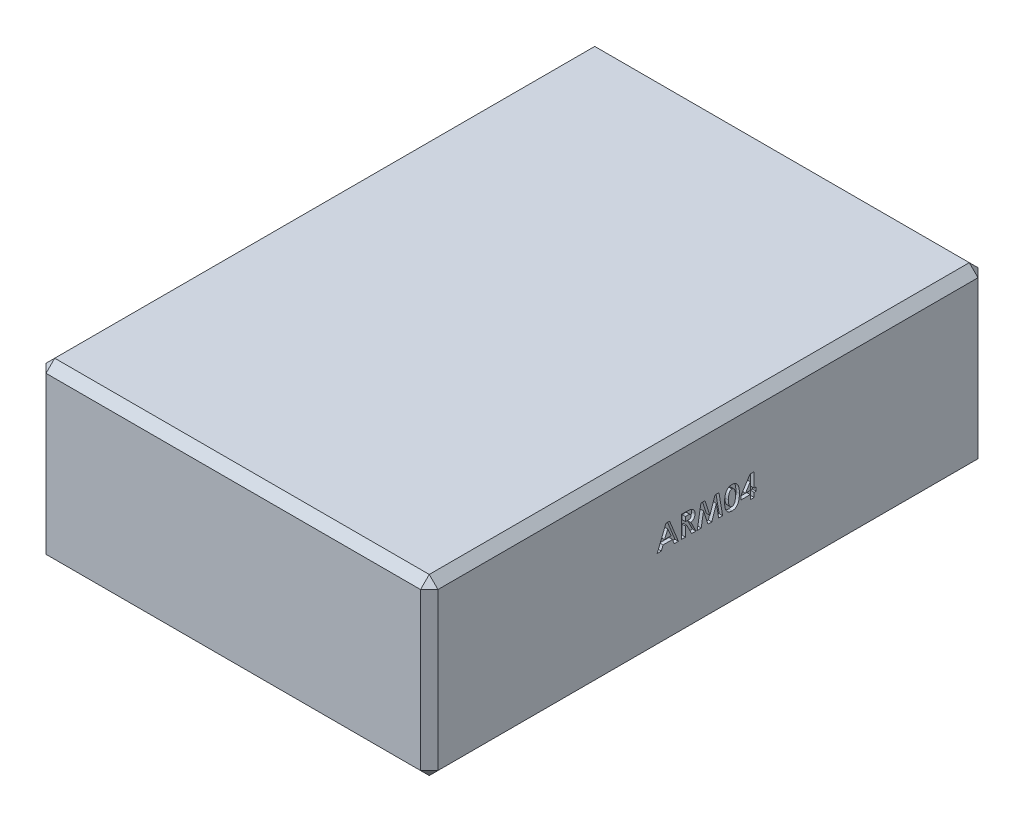
from build123d import *

# Parameters (mm, degrees)
SKETCH2_W           = 57.15
SKETCH2_H           = 25.4
BOSS_EXTRUDE1_DEPTH = 81.28
CUT_EXTRUDE1_DEPTH  = 78.74
CHAMFER1_SIZE       = 1.27
CUT_EXTRUDE2_DEPTH  = 0.508
CUT_EXTRUDE3_DEPTH  = 0.508
CHAMFER2_SIZE       = 0.508


with BuildPart() as part:
    # Sketch2 → Boss-Extrude1 (new body)
    with BuildSketch(Plane.XY):
        with Locations((0, 12.7)):
            Rectangle(SKETCH2_W, SKETCH2_H)
    extrude(amount=-BOSS_EXTRUDE1_DEPTH)

    # Sketch4 → Cut-Extrude1 (cut)
    with BuildSketch(Plane(origin=(0, 0, -81.28), x_dir=(-1, 0, 0), z_dir=(0, 0, -1))):
        with BuildLine():
            Line((-7.02184978, 0), (7.02184978, 0))
            ThreePointArc((7.02184978, 0), (6.384128426, 0.344920302), (6.323737891, 1.067423952))
            Line((6.323737891, 1.067423952), (10.301739912, 10.16))
            Line((10.301739912, 10.16), (-10.301739912, 10.16))
            Line((-10.301739912, 10.16), (-6.323737891, 1.067423952))
            ThreePointArc((-6.323737891, 1.067423952), (-6.384128426, 0.344920302), (-7.02184978, 0))
        make_face()
    extrude(amount=-CUT_EXTRUDE1_DEPTH, mode=Mode.SUBTRACT)

    # Chamfer1
    chamfer1_edges = [part.edges().sort_by_distance(p)[0] for p in [
        (28.575, 12.7, -81.28),
        (0, 25.4, -81.28),
        (-28.575, 12.7, -81.28),
        (0, 25.4, 0),
        (28.575, 12.7, 0),
        (0, 0, 0),
        (-28.575, 12.7, 0),
        (-28.575, 25.4, -40.64),
        (28.575, 25.4, -40.64),
        (28.575, 0, -40.64),
        (-28.575, 0, -40.64),
    ]]
    chamfer(chamfer1_edges, length=CHAMFER1_SIZE)

    # Sketch5 → Cut-Extrude2 (cut)
    with BuildSketch(Plane(origin=(28.575, 0, 0), x_dir=(0, 0, -1), z_dir=(1, 0, 0))):
        Polygon((34.514514223, 15.875), (35.043044872, 15.875), (36.32525641, 12.7), (35.71658754, 12.7), (35.4698127, 13.351282051), (34.086474359, 13.351282051), (33.839699519, 12.7), (33.231666667, 12.7), align=None)
        Polygon((34.778461538, 15.023372396), (34.302720353, 13.921153846), (35.254202724, 13.921153846), align=None, mode=Mode.SUBTRACT)
        with BuildLine():
            Line((36.793365385, 15.875), (37.457367788, 15.875))
            add(Edge.make_bspline(
                [(37.457367788, 15.875), (37.501258145, 15.874844214), (37.585671665, 15.874544595), (37.707391349, 15.869817392), (37.819207618, 15.863239101), (37.921286026, 15.853200455), (38.013582903, 15.839890424), (38.09619075, 15.824200099), (38.169107155, 15.80631761), (38.232947065, 15.784034619), (38.290559427, 15.758899742), (38.344262158, 15.730019307), (38.395240021, 15.697714908), (38.443152282, 15.661136528), (38.488415312, 15.620942202), (38.5311145, 15.577091473), (38.57064647, 15.529212502), (38.606766436, 15.477607826), (38.639686877, 15.42332089), (38.668781643, 15.366277157), (38.692441555, 15.306436959), (38.713347623, 15.244665114), (38.728405587, 15.180078583), (38.73887818, 15.113306125), (38.746545804, 15.044112696), (38.746986655, 14.997105753), (38.747211538, 14.973127003)],
                knots=[0, 0, 0, 0, 0.000131662, 0.000253223, 0.00036538, 0.000467651, 0.000560835, 0.000645033, 0.000719848, 0.000785822, 0.000847624, 0.000908233, 0.000968574, 0.001028488, 0.00108886, 0.00115003, 0.00121192, 0.001274915, 0.001338834, 0.001402263, 0.001466749, 0.001531714, 0.00159774, 0.001665392, 0.001734437, 0.001806332, 0.001806332, 0.001806332, 0.001806332], degree=3))
            add(Edge.make_bspline(
                [(38.747211538, 14.973127003), (38.746627373, 14.948098697), (38.74548193, 14.899022751), (38.739311954, 14.826934188), (38.728035176, 14.757964894), (38.710954855, 14.692316801), (38.691323244, 14.629172843), (38.665218237, 14.569698066), (38.635756158, 14.513027495), (38.600764906, 14.459962756), (38.562363717, 14.409325176), (38.517703942, 14.363054868), (38.469678848, 14.318664978), (38.41558877, 14.278935939), (38.357818049, 14.241181417), (38.295218842, 14.206965765), (38.228199692, 14.175428881), (38.18108191, 14.157841737), (38.156987179, 14.148848157)],
                knots=[0, 0, 0, 0, 7.5093e-05, 0.000147244, 0.000216881, 0.000284446, 0.00035062, 0.000415008, 0.000479022, 0.000542001, 0.000605481, 0.000669369, 0.000734656, 0.000801438, 0.000870416, 0.000941581, 0.001015277, 0.001092403, 0.001092403, 0.001092403, 0.001092403], degree=3))
            Line((38.156987179, 14.148848157), (38.889679487, 12.7))
            Line((38.889679487, 12.7), (38.256205929, 12.7))
            Line((38.256205929, 12.7), (37.556586538, 14.083974359))
            Line((37.556586538, 14.083974359), (37.363237179, 14.083974359))
            Line((37.363237179, 14.083974359), (37.363237179, 12.7))
            Line((37.363237179, 12.7), (36.793365385, 12.7))
            Line((36.793365385, 12.7), (36.793365385, 15.875))
        make_face()
        with BuildLine():
            Line((37.363237179, 14.653846154), (37.585207332, 14.653846154))
            add(Edge.make_bspline(
                [(37.585207332, 14.653846154), (37.612345028, 14.654151797), (37.664307885, 14.654737037), (37.739037299, 14.657451626), (37.806909428, 14.663992443), (37.868215739, 14.672256521), (37.92326472, 14.681798593), (37.971565353, 14.69547296), (38.013861877, 14.710125392), (38.049653077, 14.728334563), (38.080232255, 14.74904234), (38.106635419, 14.772566889), (38.128474621, 14.79979356), (38.146449398, 14.829982448), (38.160431821, 14.863400567), (38.170637918, 14.899681062), (38.176341617, 14.939237214), (38.176997847, 14.966536345), (38.177339744, 14.980759215)],
                knots=[0, 0, 0, 0, 8.142e-05, 0.000155902, 0.000224253, 0.000285868, 0.000341504, 0.000391652, 0.000436319, 0.000475572, 0.000511736, 0.000546861, 0.000581229, 0.000616025, 0.000651936, 0.00068959, 0.000728807, 0.000771463, 0.000771463, 0.000771463, 0.000771463], degree=3))
            add(Edge.make_bspline(
                [(38.177339744, 14.980759215), (38.176693357, 14.997585908), (38.175423651, 15.03063883), (38.162824219, 15.078223447), (38.142768645, 15.122266266), (38.115277946, 15.16256829), (38.080656985, 15.197899827), (38.040926701, 15.229044858), (37.995229618, 15.253672018), (37.952917558, 15.26991583), (37.914423473, 15.279634671), (37.879683776, 15.286877065), (37.839454998, 15.292009958), (37.793706768, 15.297454304), (37.7425557, 15.300984687), (37.68572299, 15.303561163), (37.623371862, 15.304615326), (37.579907203, 15.304952323), (37.557222556, 15.305128205)],
                knots=[0, 0, 0, 0, 5.039e-05, 9.8982e-05, 0.000146513, 0.000195026, 0.000244505, 0.000294375, 0.000345896, 0.000399642, 0.000429878, 0.000464928, 0.000506034, 0.000551477, 0.000603136, 0.000659798, 0.000722141, 0.000790198, 0.000790198, 0.000790198, 0.000790198], degree=3))
            Line((37.557222556, 15.305128205), (37.363237179, 15.305128205))
            Line((37.363237179, 15.305128205), (37.363237179, 14.653846154))
        make_face(mode=Mode.SUBTRACT)
        Polygon((39.609015425, 15.875), (40.200511819, 15.875), (40.924935897, 13.660386619), (41.654448117, 15.875), (42.240220353, 15.875), (42.777019231, 12.7), (42.200151242, 12.7), (41.861153846, 14.705363582), (41.200967548, 12.7), (40.645088141, 12.7), (39.988717949, 14.705363582), (39.650356571, 12.7), (39.072852564, 12.7), align=None)
        with BuildLine():
            add(Edge.make_bspline(
                [(44.131100761, 15.956410256), (44.158684921, 15.956000762), (44.21292275, 15.955195586), (44.292804862, 15.946474876), (44.369753423, 15.933300314), (44.444069463, 15.914926396), (44.515218049, 15.890609168), (44.583717015, 15.861501864), (44.648751025, 15.826077745), (44.71114947, 15.786064384), (44.770888315, 15.740763586), (44.826531778, 15.689118337), (44.879096027, 15.632316997), (44.92744324, 15.569500832), (44.97264408, 15.50124122), (45.014550024, 15.427527338), (45.052840274, 15.347998406), (45.08794397, 15.262510908), (45.119333806, 15.169783423), (45.145773426, 15.068752326), (45.168449824, 14.959394546), (45.187590305, 14.841437874), (45.202057414, 14.714725518), (45.211808537, 14.579341659), (45.218500219, 14.435547297), (45.219046347, 14.336905546), (45.219326923, 14.286227965)],
                knots=[0, 0, 0, 0, 8.2721e-05, 0.000162652, 0.000240761, 0.00031681, 0.000392032, 0.000466108, 0.000539812, 0.00061391, 0.000688327, 0.000764397, 0.000841366, 0.000920242, 0.001001915, 0.001086799, 0.001174413, 0.001266539, 0.001363885, 0.001467866, 0.001579631, 0.001698831, 0.001826241, 0.001962095, 0.002105975, 0.002257996, 0.002257996, 0.002257996, 0.002257996], degree=3))
            add(Edge.make_bspline(
                [(45.219326923, 14.286227965), (45.219023697, 14.23491635), (45.218434533, 14.135218804), (45.212086712, 13.990109226), (45.201155464, 13.853742398), (45.187066483, 13.72613243), (45.167768433, 13.60734671), (45.145167733, 13.497077662), (45.118310772, 13.395365257), (45.085886965, 13.302438674), (45.050995752, 13.216801041), (45.012600762, 13.137427172), (44.971371215, 13.064102077), (44.928252792, 12.99571955), (44.880881582, 12.93429547), (44.831563276, 12.8777411), (44.778150466, 12.828210667), (44.722892039, 12.783151595), (44.663763654, 12.744211514), (44.601375088, 12.710155161), (44.53461406, 12.682531414), (44.46469751, 12.658505754), (44.390433697, 12.641257923), (44.313002662, 12.627572336), (44.231530225, 12.620008841), (44.176060508, 12.619070539), (44.14763722, 12.618589744)],
                knots=[0, 0, 0, 0, 0.000153928, 0.00029908, 0.000435616, 0.00056429, 0.000684118, 0.000796506, 0.00090188, 0.000999431, 0.001091557, 0.001179171, 0.001263742, 0.00134384, 0.001421437, 0.001496228, 0.001568669, 0.00163969, 0.001709897, 0.001780758, 0.001852581, 0.001926394, 0.002002291, 0.002081026, 0.002162161, 0.002247425, 0.002247425, 0.002247425, 0.002247425], degree=3))
            add(Edge.make_bspline(
                [(44.14763722, 12.618589744), (44.119214699, 12.619079814), (44.063535398, 12.620039854), (43.981842651, 12.627516098), (43.904001271, 12.641313364), (43.829149911, 12.65863817), (43.757809527, 12.682478255), (43.689638042, 12.710928485), (43.625159637, 12.744772343), (43.564195781, 12.78380315), (43.506954621, 12.828560743), (43.452546632, 12.878566389), (43.401092165, 12.933693336), (43.353373972, 12.994559051), (43.308610566, 13.060351105), (43.267268759, 13.131820811), (43.229373397, 13.208864109), (43.193739104, 13.291588392), (43.162777415, 13.381774617), (43.135222949, 13.480228137), (43.112651055, 13.587769642), (43.094497228, 13.704364584), (43.080003223, 13.829765951), (43.069221349, 13.964034271), (43.062838268, 14.107232083), (43.062255283, 14.205659072), (43.061955128, 14.256335136)],
                knots=[0, 0, 0, 0, 8.5264e-05, 0.000167032, 0.000245767, 0.000322282, 0.000397303, 0.00047113, 0.000543675, 0.00061548, 0.000687997, 0.000761371, 0.000836975, 0.000913956, 0.000993163, 0.001075524, 0.001161424, 0.001250616, 0.001345556, 0.001447249, 0.001557148, 0.001674991, 0.001801138, 0.001935772, 0.002079018, 0.002231038, 0.002231038, 0.002231038, 0.002231038], degree=3))
            add(Edge.make_bspline(
                [(43.061955128, 14.256335136), (43.062498831, 14.326745538), (43.063547914, 14.462603314), (43.076842655, 14.6588783), (43.096355963, 14.840300526), (43.125016391, 15.006566515), (43.160454613, 15.158292069), (43.205835102, 15.294477699), (43.257497488, 15.417007839), (43.301520477, 15.489595432), (43.322722356, 15.524554287)],
                knots=[0, 0, 0, 0, 0.000211192, 0.000407498, 0.000589902, 0.000758352, 0.000913387, 0.00105679, 0.00118866, 0.001311174, 0.001311174, 0.001311174, 0.001311174], degree=3))
            add(Edge.make_bspline(
                [(43.322722356, 15.524554287), (43.34737489, 15.558897855), (43.395575452, 15.626046298), (43.479855482, 15.714199652), (43.570403401, 15.789592717), (43.669079012, 15.850519281), (43.774321719, 15.898565973), (43.887035084, 15.932500812), (44.006802876, 15.952272829), (44.089049416, 15.955010519), (44.131100761, 15.956410256)],
                knots=[0, 0, 0, 0, 0.000126695, 0.000247714, 0.000364736, 0.00047928, 0.000594555, 0.000710851, 0.000831409, 0.000957535, 0.000957535, 0.000957535, 0.000957535], degree=3))
        make_face()
        with BuildLine():
            add(Edge.make_bspline(
                [(44.145093149, 15.386538462), (44.12015684, 15.38535653), (44.071268436, 15.383039317), (44.000329033, 15.363369447), (43.933437605, 15.332988272), (43.882555083, 15.296429277), (43.844470021, 15.261383097), (43.817859715, 15.229667444), (43.792198269, 15.194275061), (43.769532787, 15.153608871), (43.748130656, 15.109130059), (43.727214323, 15.060636719), (43.710068423, 15.006937747), (43.69322303, 14.948947646), (43.678464894, 14.885063142), (43.666100811, 14.81476205), (43.65505459, 14.737587196), (43.647349719, 14.65348803), (43.640166467, 14.562552541), (43.635017172, 14.46457816), (43.632864381, 14.359591317), (43.632180074, 14.287288437), (43.631826923, 14.24997496)],
                knots=[0, 0, 0, 0, 7.4685e-05, 0.000146423, 0.000219274, 0.000294097, 0.000333247, 0.000374294, 0.000418064, 0.000464213, 0.000513709, 0.000566156, 0.000622471, 0.000682665, 0.000747308, 0.000819042, 0.000896756, 0.000981117, 0.001072336, 0.001170415, 0.001275389, 0.001387335, 0.001387335, 0.001387335, 0.001387335], degree=3))
            add(Edge.make_bspline(
                [(43.631826923, 14.24997496), (43.632408167, 14.201633547), (43.633522747, 14.108935302), (43.639360392, 13.975631999), (43.651061466, 13.85431526), (43.665615241, 13.744162875), (43.686056612, 13.645889213), (43.709575732, 13.558564514), (43.738619754, 13.483301955), (43.772185718, 13.41901307), (43.809361535, 13.36432265), (43.84971752, 13.317835547), (43.891879697, 13.277579908), (43.937164082, 13.244880749), (43.985462643, 13.219821621), (44.036372174, 13.201796899), (44.089925028, 13.190763217), (44.12659747, 13.1892332), (44.145093149, 13.188461538)],
                knots=[0, 0, 0, 0, 0.000145034, 0.000278114, 0.000400132, 0.000510587, 0.000611248, 0.00070106, 0.000781611, 0.000852734, 0.000918182, 0.000979511, 0.001037105, 0.001092704, 0.001146469, 0.001199777, 0.001254286, 0.001309751, 0.001309751, 0.001309751, 0.001309751], degree=3))
            add(Edge.make_bspline(
                [(44.145093149, 13.188461538), (44.162954115, 13.188989566), (44.197923664, 13.19002338), (44.248917099, 13.200635332), (44.297140115, 13.217888063), (44.342447111, 13.242293261), (44.385000144, 13.273328205), (44.424591241, 13.311129275), (44.460921814, 13.35607326), (44.48208817, 13.389428344), (44.492994792, 13.406615585)],
                knots=[0, 0, 0, 0, 5.352e-05, 0.000104786, 0.000155484, 0.000206702, 0.000258607, 0.000313041, 0.000370455, 0.00043149, 0.00043149, 0.00043149, 0.00043149], degree=3))
            add(Edge.make_bspline(
                [(44.492994792, 13.406615585), (44.505835501, 13.4301014), (44.532761428, 13.47934925), (44.563920158, 13.562453161), (44.590147839, 13.656180636), (44.612721621, 13.760823366), (44.628160711, 13.876794074), (44.641456837, 14.00335738), (44.647869888, 14.141150605), (44.648913006, 14.236614248), (44.649455128, 14.286227965)],
                knots=[0, 0, 0, 0, 8.0219e-05, 0.000168213, 0.000265448, 0.000372104, 0.000489035, 0.00061624, 0.000753798, 0.000902648, 0.000902648, 0.000902648, 0.000902648], degree=3))
            add(Edge.make_bspline(
                [(44.649455128, 14.286227965), (44.649245718, 14.336272352), (44.64884264, 14.432599256), (44.641447314, 14.570887857), (44.631148759, 14.697191543), (44.616084946, 14.81122833), (44.596702612, 14.913275048), (44.572813812, 15.003325026), (44.544650694, 15.081555737), (44.511252592, 15.147889172), (44.47426212, 15.204263493), (44.434995604, 15.252628288), (44.39328701, 15.293920929), (44.349206089, 15.328296808), (44.301732571, 15.354562559), (44.251773263, 15.373108351), (44.199225745, 15.384327934), (44.163380899, 15.385791673), (44.145093149, 15.386538462)],
                knots=[0, 0, 0, 0, 0.000150112, 0.000288941, 0.000415335, 0.000530201, 0.000633857, 0.000726735, 0.000809439, 0.000882824, 0.000948976, 0.001011358, 0.001069375, 0.001124712, 0.001178518, 0.001231446, 0.001284085, 0.001338916, 0.001338916, 0.001338916, 0.001338916], degree=3))
        make_face(mode=Mode.SUBTRACT)
        Polygon((46.782658253, 15.956410256), (47.376698718, 15.956410256), (47.376698718, 13.880448718), (47.661634615, 13.880448718), (47.661634615, 13.351282051), (47.376698718, 13.351282051), (47.376698718, 12.7), (46.806826923, 12.7), (46.806826923, 13.351282051), (45.463557692, 13.351282051), (45.463557692, 13.92815004), align=None)
        Polygon((46.806826923, 13.880448718), (46.806826923, 14.961042668), (46.104027444, 13.880448718), align=None, mode=Mode.SUBTRACT)
    extrude(amount=-CUT_EXTRUDE2_DEPTH, mode=Mode.SUBTRACT)

    # Sketch6 → Cut-Extrude3 (cut)
    with BuildSketch(Plane.ZY.offset(28.575)):
        Polygon((-46.765485777, 15.875), (-46.236955128, 15.875), (-44.95474359, 12.7), (-45.56341246, 12.7), (-45.8101873, 13.351282051), (-47.193525641, 13.351282051), (-47.440300481, 12.7), (-48.048333333, 12.7), align=None)
        Polygon((-46.501538462, 15.023372396), (-46.977279647, 13.921153846), (-46.025797276, 13.921153846), align=None, mode=Mode.SUBTRACT)
        with BuildLine():
            Line((-44.486634615, 15.875), (-43.822632212, 15.875))
            add(Edge.make_bspline(
                [(-43.822632212, 15.875), (-43.778741855, 15.874844214), (-43.694328335, 15.874544595), (-43.572608651, 15.869817392), (-43.460792382, 15.863239101), (-43.358713974, 15.853200455), (-43.266417097, 15.839890424), (-43.18380925, 15.824200099), (-43.110892845, 15.80631761), (-43.047052935, 15.784034619), (-42.989440573, 15.758899742), (-42.935737842, 15.730019307), (-42.884759979, 15.697714908), (-42.836847718, 15.661136528), (-42.791584688, 15.620942202), (-42.7488855, 15.577091473), (-42.70935353, 15.529212502), (-42.673233564, 15.477607826), (-42.640313123, 15.42332089), (-42.611218357, 15.366277157), (-42.587558445, 15.306436959), (-42.566652377, 15.244665114), (-42.551594413, 15.180078583), (-42.54112182, 15.113306125), (-42.533454196, 15.044112696), (-42.533013345, 14.997105753), (-42.532788462, 14.973127003)],
                knots=[0, 0, 0, 0, 0.000131662, 0.000253223, 0.00036538, 0.000467651, 0.000560835, 0.000645033, 0.000719848, 0.000785822, 0.000847624, 0.000908233, 0.000968574, 0.001028488, 0.00108886, 0.00115003, 0.00121192, 0.001274915, 0.001338834, 0.001402263, 0.001466749, 0.001531714, 0.00159774, 0.001665392, 0.001734437, 0.001806332, 0.001806332, 0.001806332, 0.001806332], degree=3))
            add(Edge.make_bspline(
                [(-42.532788462, 14.973127003), (-42.533372627, 14.948098697), (-42.53451807, 14.899022751), (-42.540688046, 14.826934188), (-42.551964824, 14.757964894), (-42.569045145, 14.692316801), (-42.588676756, 14.629172843), (-42.614781763, 14.569698066), (-42.644243842, 14.513027495), (-42.679235094, 14.459962756), (-42.717636283, 14.409325176), (-42.762296058, 14.363054868), (-42.810321152, 14.318664978), (-42.86441123, 14.278935939), (-42.922181951, 14.241181417), (-42.984781158, 14.206965765), (-43.051800308, 14.175428881), (-43.09891809, 14.157841737), (-43.123012821, 14.148848157)],
                knots=[0, 0, 0, 0, 7.5093e-05, 0.000147244, 0.000216881, 0.000284446, 0.00035062, 0.000415008, 0.000479022, 0.000542001, 0.000605481, 0.000669369, 0.000734656, 0.000801438, 0.000870416, 0.000941581, 0.001015277, 0.001092403, 0.001092403, 0.001092403, 0.001092403], degree=3))
            Line((-43.123012821, 14.148848157), (-42.390320513, 12.7))
            Line((-42.390320513, 12.7), (-43.023794071, 12.7))
            Line((-43.023794071, 12.7), (-43.723413462, 14.083974359))
            Line((-43.723413462, 14.083974359), (-43.916762821, 14.083974359))
            Line((-43.916762821, 14.083974359), (-43.916762821, 12.7))
            Line((-43.916762821, 12.7), (-44.486634615, 12.7))
            Line((-44.486634615, 12.7), (-44.486634615, 15.875))
        make_face()
        with BuildLine():
            Line((-43.916762821, 14.653846154), (-43.694792668, 14.653846154))
            add(Edge.make_bspline(
                [(-43.694792668, 14.653846154), (-43.667654972, 14.654151797), (-43.615692115, 14.654737037), (-43.540962701, 14.657451626), (-43.473090572, 14.663992443), (-43.411784261, 14.672256521), (-43.35673528, 14.681798593), (-43.308434647, 14.69547296), (-43.266138123, 14.710125392), (-43.230346923, 14.728334563), (-43.199767745, 14.74904234), (-43.173364581, 14.772566889), (-43.151525379, 14.79979356), (-43.133550602, 14.829982448), (-43.119568179, 14.863400567), (-43.109362082, 14.899681062), (-43.103658383, 14.939237214), (-43.103002153, 14.966536345), (-43.102660256, 14.980759215)],
                knots=[0, 0, 0, 0, 8.142e-05, 0.000155902, 0.000224253, 0.000285868, 0.000341504, 0.000391652, 0.000436319, 0.000475572, 0.000511736, 0.000546861, 0.000581229, 0.000616025, 0.000651936, 0.00068959, 0.000728807, 0.000771463, 0.000771463, 0.000771463, 0.000771463], degree=3))
            add(Edge.make_bspline(
                [(-43.102660256, 14.980759215), (-43.103306643, 14.997585908), (-43.104576349, 15.03063883), (-43.117175781, 15.078223447), (-43.137231355, 15.122266266), (-43.164722054, 15.16256829), (-43.199343015, 15.197899827), (-43.239073299, 15.229044858), (-43.284770382, 15.253672018), (-43.327082442, 15.26991583), (-43.365576527, 15.279634671), (-43.400316224, 15.286877065), (-43.440545002, 15.292009958), (-43.486293232, 15.297454304), (-43.5374443, 15.300984687), (-43.59427701, 15.303561163), (-43.656628138, 15.304615326), (-43.700092797, 15.304952323), (-43.722777444, 15.305128205)],
                knots=[0, 0, 0, 0, 5.039e-05, 9.8982e-05, 0.000146513, 0.000195026, 0.000244505, 0.000294375, 0.000345896, 0.000399642, 0.000429878, 0.000464928, 0.000506034, 0.000551477, 0.000603136, 0.000659798, 0.000722141, 0.000790198, 0.000790198, 0.000790198, 0.000790198], degree=3))
            Line((-43.722777444, 15.305128205), (-43.916762821, 15.305128205))
            Line((-43.916762821, 15.305128205), (-43.916762821, 14.653846154))
        make_face(mode=Mode.SUBTRACT)
        Polygon((-41.670984575, 15.875), (-41.079488181, 15.875), (-40.355064103, 13.660386619), (-39.625551883, 15.875), (-39.039779647, 15.875), (-38.502980769, 12.7), (-39.079848758, 12.7), (-39.418846154, 14.705363582), (-40.079032452, 12.7), (-40.634911859, 12.7), (-41.291282051, 14.705363582), (-41.629643429, 12.7), (-42.207147436, 12.7), align=None)
        with BuildLine():
            add(Edge.make_bspline(
                [(-37.148899239, 15.956410256), (-37.121315079, 15.956000762), (-37.06707725, 15.955195586), (-36.987195138, 15.946474876), (-36.910246577, 15.933300314), (-36.835930537, 15.914926396), (-36.764781951, 15.890609168), (-36.696282985, 15.861501864), (-36.631248975, 15.826077745), (-36.56885053, 15.786064384), (-36.509111685, 15.740763586), (-36.453468222, 15.689118337), (-36.400903973, 15.632316997), (-36.35255676, 15.569500832), (-36.30735592, 15.50124122), (-36.265449976, 15.427527338), (-36.227159726, 15.347998406), (-36.19205603, 15.262510908), (-36.160666194, 15.169783423), (-36.134226574, 15.068752326), (-36.111550176, 14.959394546), (-36.092409695, 14.841437874), (-36.077942586, 14.714725518), (-36.068191463, 14.579341659), (-36.061499781, 14.435547297), (-36.060953653, 14.336905546), (-36.060673077, 14.286227965)],
                knots=[0, 0, 0, 0, 8.2721e-05, 0.000162652, 0.000240761, 0.00031681, 0.000392032, 0.000466108, 0.000539812, 0.00061391, 0.000688327, 0.000764397, 0.000841366, 0.000920242, 0.001001915, 0.001086799, 0.001174413, 0.001266539, 0.001363885, 0.001467866, 0.001579631, 0.001698831, 0.001826241, 0.001962095, 0.002105975, 0.002257996, 0.002257996, 0.002257996, 0.002257996], degree=3))
            add(Edge.make_bspline(
                [(-36.060673077, 14.286227965), (-36.060976303, 14.23491635), (-36.061565467, 14.135218804), (-36.067913288, 13.990109226), (-36.078844536, 13.853742398), (-36.092933517, 13.72613243), (-36.112231567, 13.60734671), (-36.134832267, 13.497077662), (-36.161689228, 13.395365257), (-36.194113035, 13.302438674), (-36.229004248, 13.216801041), (-36.267399238, 13.137427172), (-36.308628785, 13.064102077), (-36.351747208, 12.99571955), (-36.399118418, 12.93429547), (-36.448436724, 12.8777411), (-36.501849534, 12.828210667), (-36.557107961, 12.783151595), (-36.616236346, 12.744211514), (-36.678624912, 12.710155161), (-36.74538594, 12.682531414), (-36.81530249, 12.658505754), (-36.889566303, 12.641257923), (-36.966997338, 12.627572336), (-37.048469775, 12.620008841), (-37.103939492, 12.619070539), (-37.13236278, 12.618589744)],
                knots=[0, 0, 0, 0, 0.000153928, 0.00029908, 0.000435616, 0.00056429, 0.000684118, 0.000796506, 0.00090188, 0.000999431, 0.001091557, 0.001179171, 0.001263742, 0.00134384, 0.001421437, 0.001496228, 0.001568669, 0.00163969, 0.001709897, 0.001780758, 0.001852581, 0.001926394, 0.002002291, 0.002081026, 0.002162161, 0.002247425, 0.002247425, 0.002247425, 0.002247425], degree=3))
            add(Edge.make_bspline(
                [(-37.13236278, 12.618589744), (-37.160785301, 12.619079814), (-37.216464602, 12.620039854), (-37.298157349, 12.627516098), (-37.375998729, 12.641313364), (-37.450850089, 12.65863817), (-37.522190473, 12.682478255), (-37.590361958, 12.710928485), (-37.654840363, 12.744772343), (-37.715804219, 12.78380315), (-37.773045379, 12.828560743), (-37.827453368, 12.878566389), (-37.878907835, 12.933693336), (-37.926626028, 12.994559051), (-37.971389434, 13.060351105), (-38.012731241, 13.131820811), (-38.050626603, 13.208864109), (-38.086260896, 13.291588392), (-38.117222585, 13.381774617), (-38.144777051, 13.480228137), (-38.167348945, 13.587769642), (-38.185502772, 13.704364584), (-38.199996777, 13.829765951), (-38.210778651, 13.964034271), (-38.217161732, 14.107232083), (-38.217744717, 14.205659072), (-38.218044872, 14.256335136)],
                knots=[0, 0, 0, 0, 8.5264e-05, 0.000167032, 0.000245767, 0.000322282, 0.000397303, 0.00047113, 0.000543675, 0.00061548, 0.000687997, 0.000761371, 0.000836975, 0.000913956, 0.000993163, 0.001075524, 0.001161424, 0.001250616, 0.001345556, 0.001447249, 0.001557148, 0.001674991, 0.001801138, 0.001935772, 0.002079018, 0.002231038, 0.002231038, 0.002231038, 0.002231038], degree=3))
            add(Edge.make_bspline(
                [(-38.218044872, 14.256335136), (-38.217501169, 14.326745538), (-38.216452086, 14.462603314), (-38.203157345, 14.6588783), (-38.183644037, 14.840300526), (-38.154983609, 15.006566515), (-38.119545387, 15.158292069), (-38.074164898, 15.294477699), (-38.022502512, 15.417007839), (-37.978479523, 15.489595432), (-37.957277644, 15.524554287)],
                knots=[0, 0, 0, 0, 0.000211192, 0.000407498, 0.000589902, 0.000758352, 0.000913387, 0.00105679, 0.00118866, 0.001311174, 0.001311174, 0.001311174, 0.001311174], degree=3))
            add(Edge.make_bspline(
                [(-37.957277644, 15.524554287), (-37.93262511, 15.558897855), (-37.884424548, 15.626046298), (-37.800144518, 15.714199652), (-37.709596599, 15.789592717), (-37.610920988, 15.850519281), (-37.505678281, 15.898565973), (-37.392964916, 15.932500812), (-37.273197124, 15.952272829), (-37.190950584, 15.955010519), (-37.148899239, 15.956410256)],
                knots=[0, 0, 0, 0, 0.000126695, 0.000247714, 0.000364736, 0.00047928, 0.000594555, 0.000710851, 0.000831409, 0.000957535, 0.000957535, 0.000957535, 0.000957535], degree=3))
        make_face()
        with BuildLine():
            add(Edge.make_bspline(
                [(-37.134906851, 15.386538462), (-37.15984316, 15.38535653), (-37.208731564, 15.383039317), (-37.279670967, 15.363369447), (-37.346562395, 15.332988272), (-37.397444917, 15.296429277), (-37.435529979, 15.261383097), (-37.462140285, 15.229667444), (-37.487801731, 15.194275061), (-37.510467213, 15.153608871), (-37.531869344, 15.109130059), (-37.552785677, 15.060636719), (-37.569931577, 15.006937747), (-37.58677697, 14.948947646), (-37.601535106, 14.885063142), (-37.613899189, 14.81476205), (-37.62494541, 14.737587196), (-37.632650281, 14.65348803), (-37.639833533, 14.562552541), (-37.644982828, 14.46457816), (-37.647135619, 14.359591317), (-37.647819926, 14.287288437), (-37.648173077, 14.24997496)],
                knots=[0, 0, 0, 0, 7.4685e-05, 0.000146423, 0.000219274, 0.000294097, 0.000333247, 0.000374294, 0.000418064, 0.000464213, 0.000513709, 0.000566156, 0.000622471, 0.000682665, 0.000747308, 0.000819042, 0.000896756, 0.000981117, 0.001072336, 0.001170415, 0.001275389, 0.001387335, 0.001387335, 0.001387335, 0.001387335], degree=3))
            add(Edge.make_bspline(
                [(-37.648173077, 14.24997496), (-37.647591833, 14.201633547), (-37.646477253, 14.108935302), (-37.640639608, 13.975631999), (-37.628938534, 13.85431526), (-37.614384759, 13.744162875), (-37.593943388, 13.645889213), (-37.570424268, 13.558564514), (-37.541380246, 13.483301955), (-37.507814282, 13.41901307), (-37.470638465, 13.36432265), (-37.43028248, 13.317835547), (-37.388120303, 13.277579908), (-37.342835918, 13.244880749), (-37.294537357, 13.219821621), (-37.243627826, 13.201796899), (-37.190074972, 13.190763217), (-37.15340253, 13.1892332), (-37.134906851, 13.188461538)],
                knots=[0, 0, 0, 0, 0.000145034, 0.000278114, 0.000400132, 0.000510587, 0.000611248, 0.00070106, 0.000781611, 0.000852734, 0.000918182, 0.000979511, 0.001037105, 0.001092704, 0.001146469, 0.001199777, 0.001254286, 0.001309751, 0.001309751, 0.001309751, 0.001309751], degree=3))
            add(Edge.make_bspline(
                [(-37.134906851, 13.188461538), (-37.117045885, 13.188989566), (-37.082076336, 13.19002338), (-37.031082901, 13.200635332), (-36.982859885, 13.217888063), (-36.937552889, 13.242293261), (-36.894999856, 13.273328205), (-36.855408759, 13.311129275), (-36.819078186, 13.35607326), (-36.79791183, 13.389428344), (-36.787005208, 13.406615585)],
                knots=[0, 0, 0, 0, 5.352e-05, 0.000104786, 0.000155484, 0.000206702, 0.000258607, 0.000313041, 0.000370455, 0.00043149, 0.00043149, 0.00043149, 0.00043149], degree=3))
            add(Edge.make_bspline(
                [(-36.787005208, 13.406615585), (-36.774164499, 13.4301014), (-36.747238572, 13.47934925), (-36.716079842, 13.562453161), (-36.689852161, 13.656180636), (-36.667278379, 13.760823366), (-36.651839289, 13.876794074), (-36.638543163, 14.00335738), (-36.632130112, 14.141150605), (-36.631086994, 14.236614248), (-36.630544872, 14.286227965)],
                knots=[0, 0, 0, 0, 8.0219e-05, 0.000168213, 0.000265448, 0.000372104, 0.000489035, 0.00061624, 0.000753798, 0.000902648, 0.000902648, 0.000902648, 0.000902648], degree=3))
            add(Edge.make_bspline(
                [(-36.630544872, 14.286227965), (-36.630754282, 14.336272352), (-36.63115736, 14.432599256), (-36.638552686, 14.570887857), (-36.648851241, 14.697191543), (-36.663915054, 14.81122833), (-36.683297388, 14.913275048), (-36.707186188, 15.003325026), (-36.735349306, 15.081555737), (-36.768747408, 15.147889172), (-36.80573788, 15.204263493), (-36.845004396, 15.252628288), (-36.88671299, 15.293920929), (-36.930793911, 15.328296808), (-36.978267429, 15.354562559), (-37.028226737, 15.373108351), (-37.080774255, 15.384327934), (-37.116619101, 15.385791673), (-37.134906851, 15.386538462)],
                knots=[0, 0, 0, 0, 0.000150112, 0.000288941, 0.000415335, 0.000530201, 0.000633857, 0.000726735, 0.000809439, 0.000882824, 0.000948976, 0.001011358, 0.001069375, 0.001124712, 0.001178518, 0.001231446, 0.001284085, 0.001338916, 0.001338916, 0.001338916, 0.001338916], degree=3))
        make_face(mode=Mode.SUBTRACT)
        Polygon((-34.497341747, 15.956410256), (-33.903301282, 15.956410256), (-33.903301282, 13.880448718), (-33.618365385, 13.880448718), (-33.618365385, 13.351282051), (-33.903301282, 13.351282051), (-33.903301282, 12.7), (-34.473173077, 12.7), (-34.473173077, 13.351282051), (-35.816442308, 13.351282051), (-35.816442308, 13.92815004), align=None)
        Polygon((-34.473173077, 13.880448718), (-34.473173077, 14.961042668), (-35.175972556, 13.880448718), align=None, mode=Mode.SUBTRACT)
    extrude(amount=-CUT_EXTRUDE3_DEPTH, mode=Mode.SUBTRACT)

    # Chamfer2
    chamfer2_edges = [part.edges().sort_by_distance(p)[0] for p in [
        (17.16342489, 0, -81.28),
        (-6.384128426, 0.344920302, -81.28),
        (-8.312738901, 5.613711976, -81.28),
        (0, 10.16, -81.28),
        (8.312738901, 5.613711976, -81.28),
        (6.384128426, 0.344920302, -81.28),
        (-17.16342489, 0, -81.28),
    ]]
    chamfer(chamfer2_edges, length=CHAMFER2_SIZE)


solid = part.part
